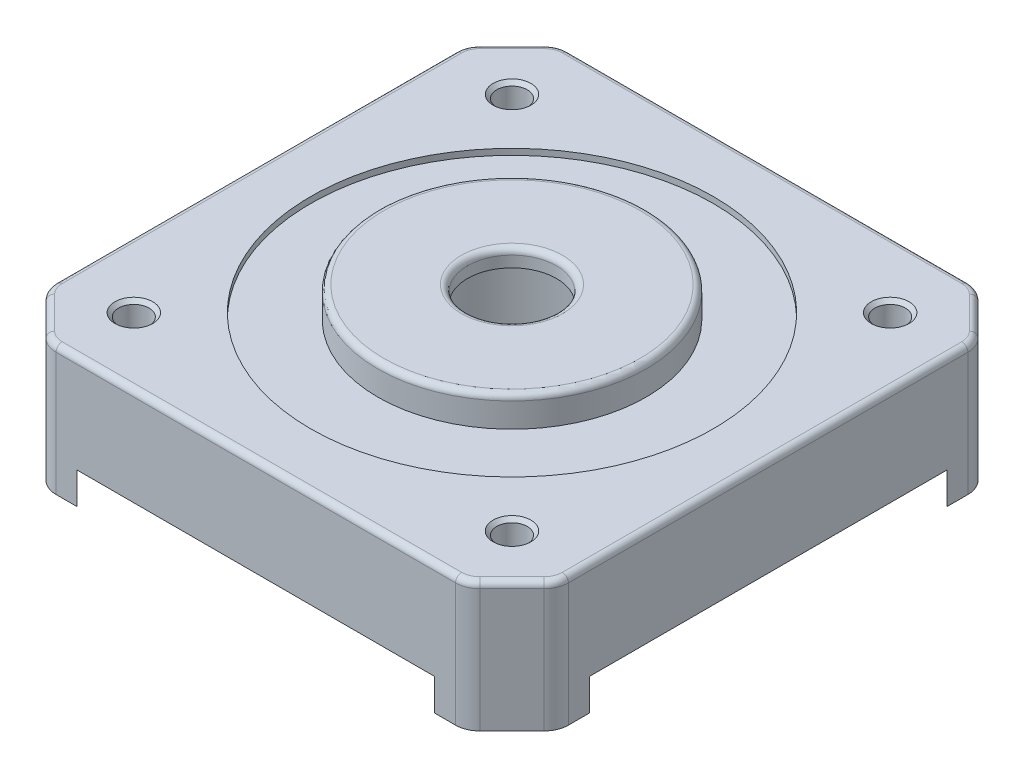
from build123d import *

# Parameters (mm, degrees)
SKETCH_1_R          = 2.65
SKETCH_1_R_2        = 16.5
SKETCH_1_R_3        = 1.25
EXTRUDE_1_DEPTH     = 8
SKETCH_1_3_R        = 16.5
SKETCH_1_3_R_2      = 11
EXTRUDE_2_DEPTH     = 7.5
SKETCH_1_4_R        = 11
SKETCH_1_4_R_2      = 3.65
EXTRUDE_3_DEPTH     = 10
EXTRUDE_4_DEPTH     = 2.6
SKETCH_2_R          = 8
CUT_EXTRUDE_1_DEPTH = 8.6
FILLET_1_R          = 2
FILLET_2_R          = 0.5
CHAMFER_1_SIZE      = 0.3


with BuildPart() as part:
    # Sketch 1 → Extrude 1 (new body)
    with BuildSketch(Plane(origin=(0, 0, 0), x_dir=(1, 0, 0), z_dir=(0, 1, 0))):
        with BuildLine():
            ThreePointArc((-14.641038215, 21), (-18.101933598, 18.101933598), (-21, 14.641038215))
            Line((-21, 14.641038215), (-21, -14.641038215))
            ThreePointArc((-21, -14.641038215), (-18.101933598, -18.101933598), (-14.641038215, -21))
            Line((-14.641038215, -21), (14.641038215, -21))
            ThreePointArc((14.641038215, -21), (18.101933598, -18.101933598), (21, -14.641038215))
            Line((21, -14.641038215), (21, 14.641038215))
            ThreePointArc((21, 14.641038215), (18.101933598, 18.101933598), (14.641038215, 21))
            Line((14.641038215, 21), (-14.641038215, 21))
        make_face()
        with Locations((-15.5, -15.5)):
            Circle(SKETCH_1_R, mode=Mode.SUBTRACT)
        with Locations((15.5, -15.5)):
            Circle(SKETCH_1_R, mode=Mode.SUBTRACT)
        Circle(SKETCH_1_R_2, mode=Mode.SUBTRACT)
        with Locations((-15.5, 15.5)):
            Circle(SKETCH_1_R, mode=Mode.SUBTRACT)
        with Locations((15.5, 15.5)):
            Circle(SKETCH_1_R, mode=Mode.SUBTRACT)
        with Locations((15.5, -15.5)):
            Circle(SKETCH_1_R)
        with Locations((15.5, -15.5)):
            Circle(SKETCH_1_R_3, mode=Mode.SUBTRACT)
        with Locations((-15.5, -15.5)):
            Circle(SKETCH_1_R)
        with Locations((-15.5, -15.5)):
            Circle(SKETCH_1_R_3, mode=Mode.SUBTRACT)
        with Locations((-15.5, 15.5)):
            Circle(SKETCH_1_R)
        with Locations((-15.5, 15.5)):
            Circle(SKETCH_1_R_3, mode=Mode.SUBTRACT)
        with Locations((15.5, 15.5)):
            Circle(SKETCH_1_R)
        with Locations((15.5, 15.5)):
            Circle(SKETCH_1_R_3, mode=Mode.SUBTRACT)
        with BuildLine():
            ThreePointArc((-14.641038215, -21), (-18.101933598, -18.101933598), (-21, -14.641038215))
            Line((-21, -14.641038215), (-21, -17.2))
            Line((-21, -17.2), (-17.2, -21))
            Line((-17.2, -21), (-14.641038215, -21))
        make_face()
        with BuildLine():
            Line((-17.2, 21), (-21, 17.2))
            Line((-21, 17.2), (-21, 14.641038215))
            ThreePointArc((-21, 14.641038215), (-18.101933598, 18.101933598), (-14.641038215, 21))
            Line((-14.641038215, 21), (-17.2, 21))
        make_face()
        with BuildLine():
            Line((17.2, 21), (14.641038215, 21))
            ThreePointArc((14.641038215, 21), (18.101933598, 18.101933598), (21, 14.641038215))
            Line((21, 14.641038215), (21, 17.2))
            Line((21, 17.2), (17.2, 21))
        make_face()
        with BuildLine():
            ThreePointArc((21, -14.641038215), (18.101933598, -18.101933598), (14.641038215, -21))
            Line((14.641038215, -21), (17.2, -21))
            Line((17.2, -21), (21, -17.2))
            Line((21, -17.2), (21, -14.641038215))
        make_face()
    extrude(amount=EXTRUDE_1_DEPTH)

    # Sketch 1_3 → Extrude 2 (add)
    with BuildSketch(Plane(origin=(0, 0, 0), x_dir=(1, 0, 0), z_dir=(0, 1, 0))):
        Circle(SKETCH_1_3_R)
        Circle(SKETCH_1_3_R_2, mode=Mode.SUBTRACT)
    extrude(amount=EXTRUDE_2_DEPTH)

    # Sketch 1_4 → Extrude 3 (add)
    with BuildSketch(Plane(origin=(0, 0, 0), x_dir=(1, 0, 0), z_dir=(0, 1, 0))):
        Circle(SKETCH_1_4_R)
        Circle(SKETCH_1_4_R_2, mode=Mode.SUBTRACT)
    extrude(amount=EXTRUDE_3_DEPTH)

    # Sketch 1_5 → Extrude 4 (add)
    with BuildSketch(Plane(origin=(0, 0, 0), x_dir=(1, 0, 0), z_dir=(0, 1, 0))):
        with BuildLine():
            ThreePointArc((-14.641038215, -21), (-18.101933598, -18.101933598), (-21, -14.641038215))
            Line((-21, -14.641038215), (-21, -17.2))
            Line((-21, -17.2), (-17.2, -21))
            Line((-17.2, -21), (-14.641038215, -21))
        make_face()
        with BuildLine():
            ThreePointArc((21, -14.641038215), (18.101933598, -18.101933598), (14.641038215, -21))
            Line((14.641038215, -21), (17.2, -21))
            Line((17.2, -21), (21, -17.2))
            Line((21, -17.2), (21, -14.641038215))
        make_face()
        with BuildLine():
            Line((-17.2, 21), (-21, 17.2))
            Line((-21, 17.2), (-21, 14.641038215))
            ThreePointArc((-21, 14.641038215), (-18.101933598, 18.101933598), (-14.641038215, 21))
            Line((-14.641038215, 21), (-17.2, 21))
        make_face()
        with BuildLine():
            Line((17.2, 21), (14.641038215, 21))
            ThreePointArc((14.641038215, 21), (18.101933598, 18.101933598), (21, 14.641038215))
            Line((21, 14.641038215), (21, 17.2))
            Line((21, 17.2), (17.2, 21))
        make_face()
    extrude(amount=-EXTRUDE_4_DEPTH)

    # Sketch 2 → Cut-Extrude 1 (cut)
    with BuildSketch(Plane.XZ):
        Circle(SKETCH_2_R)
    extrude(amount=-CUT_EXTRUDE_1_DEPTH, mode=Mode.SUBTRACT)

    # Fillet 1
    fillet_1_edges = [part.edges().sort_by_distance(p)[0] for p in [
        (-17.2, 2.7, 21),
        (-21, 2.7, 17.2),
        (-21, 2.7, -17.2),
        (-17.2, 2.7, -21),
        (17.2, 2.7, -21),
        (21, 2.7, -17.2),
        (21, 2.7, 17.2),
        (17.2, 2.7, 21),
    ]]
    fillet(fillet_1_edges, radius=FILLET_1_R)

    # Fillet 2
    fillet_2_edges = [part.edges().sort_by_distance(p)[0] for p in [
        (21, 8, 0),
        (19.1, 8, 19.1),
        (0, 8, 21),
        (19.1, 8, -19.1),
        (0, 8, -21),
        (-19.1, 8, -19.1),
        (-21, 8, 0),
        (-19.1, 8, 19.1),
        (20.847759065, 8, -17.13693974),
        (17.13693974, 8, -20.847759065),
        (-17.13693974, 8, -20.847759065),
        (-20.847759065, 8, -17.13693974),
        (-20.847759065, 8, 17.13693974),
        (-17.13693974, 8, 20.847759065),
        (17.13693974, 8, 20.847759065),
        (20.847759065, 8, 17.13693974),
        (-3.65, 10, 0),
        (-11, 10, 0),
    ]]
    fillet(fillet_2_edges, radius=FILLET_2_R)

    # Chamfer 1
    chamfer_1_edges = [part.edges().sort_by_distance(p)[0] for p in [
        (-16.75, 8, -15.5),
        (14.25, 8, -15.5),
        (14.25, 8, 15.5),
        (-16.75, 8, 15.5),
    ]]
    chamfer(chamfer_1_edges, length=CHAMFER_1_SIZE)


solid = part.part
